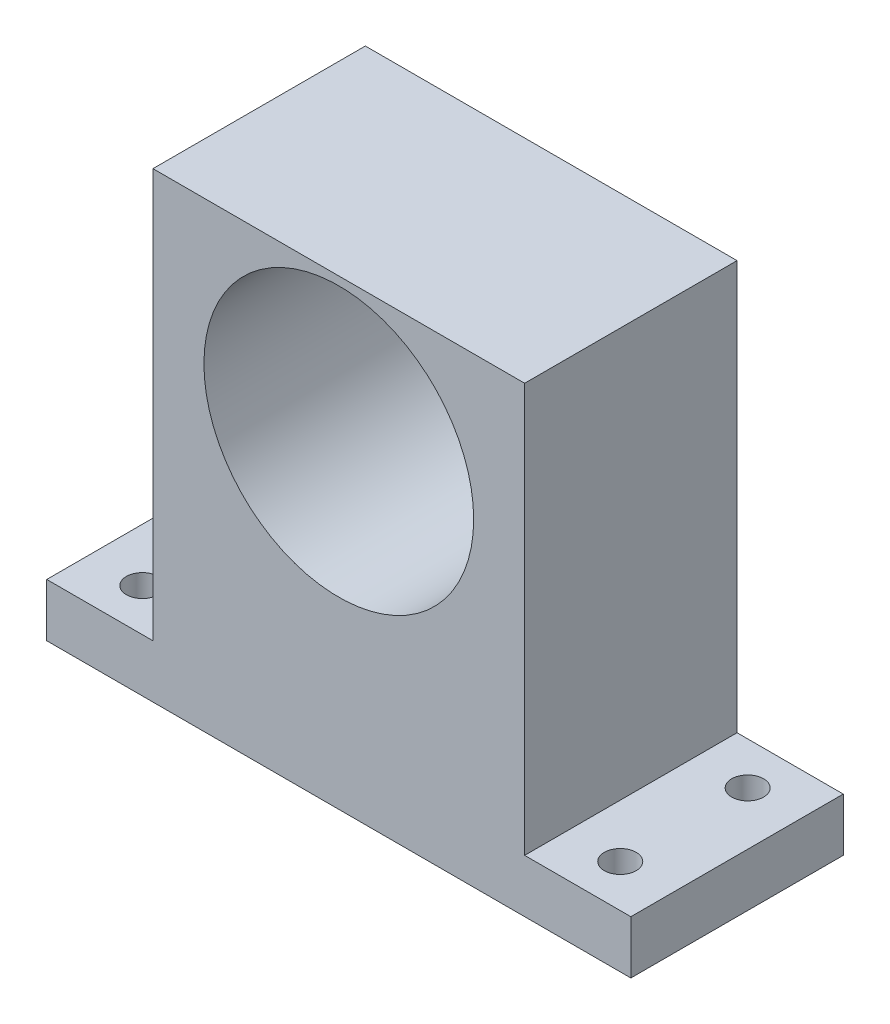
from build123d import *

# Parameters (mm, degrees)
SKETCH_1_W          = 35
SKETCH_1_H          = 43.5
EXTRUDE_1_DEPTH     = 20
SKETCH_2_W          = 20
SKETCH_2_H          = 5
EXTRUDE_2_DEPTH     = 10
SKETCH_3_W          = 20
SKETCH_3_H          = 5
EXTRUDE_3_DEPTH     = 10
SKETCH_4_R          = 1.5
CUT_EXTRUDE_2_DEPTH = 5
SKETCH_5_R          = 12.7
CUT_EXTRUDE_3_DEPTH = 20


with BuildPart() as part:
    # Эскиз1 → Бобышка-Вытянуть1 (new body)
    with BuildSketch(Plane.XY):
        Rectangle(SKETCH_1_W, SKETCH_1_H)
    extrude(amount=EXTRUDE_1_DEPTH)

    # Эскиз2 → Бобышка-Вытянуть2 (add)
    with BuildSketch(Plane(origin=(17.5, 0, 0), x_dir=(0, 0, -1), z_dir=(1, 0, 0))):
        with Locations((-10, -19.25)):
            Rectangle(SKETCH_2_W, SKETCH_2_H)
    extrude(amount=EXTRUDE_2_DEPTH)

    # Эскиз3 → Бобышка-Вытянуть3 (add)
    with BuildSketch(Plane.ZY.offset(17.5)):
        with Locations((10, -19.25)):
            Rectangle(SKETCH_3_W, SKETCH_3_H)
    extrude(amount=EXTRUDE_3_DEPTH)

    # Эскиз4 → Вырез-Вытянуть2 (cut)
    with BuildSketch(Plane(origin=(0, -16.75, 0), x_dir=(1, 0, 0), z_dir=(0, 1, 0))):
        with Locations((-22.5, -16)):
            Circle(SKETCH_4_R)
        with Locations((-22.5, -4)):
            Circle(SKETCH_4_R)
        with Locations((22.5, -16)):
            Circle(SKETCH_4_R)
        with Locations((22.5, -4)):
            Circle(SKETCH_4_R)
    extrude(amount=-CUT_EXTRUDE_2_DEPTH, mode=Mode.SUBTRACT)

    # Эскиз5 → Вырез-Вытянуть3 (cut)
    with BuildSketch(Plane(origin=(0, 0, 0), x_dir=(-1, 0, 0), z_dir=(0, 0, -1))):
        with Locations((0, 8.25)):
            Circle(SKETCH_5_R)
    extrude(amount=-CUT_EXTRUDE_3_DEPTH, mode=Mode.SUBTRACT)


solid = part.part
